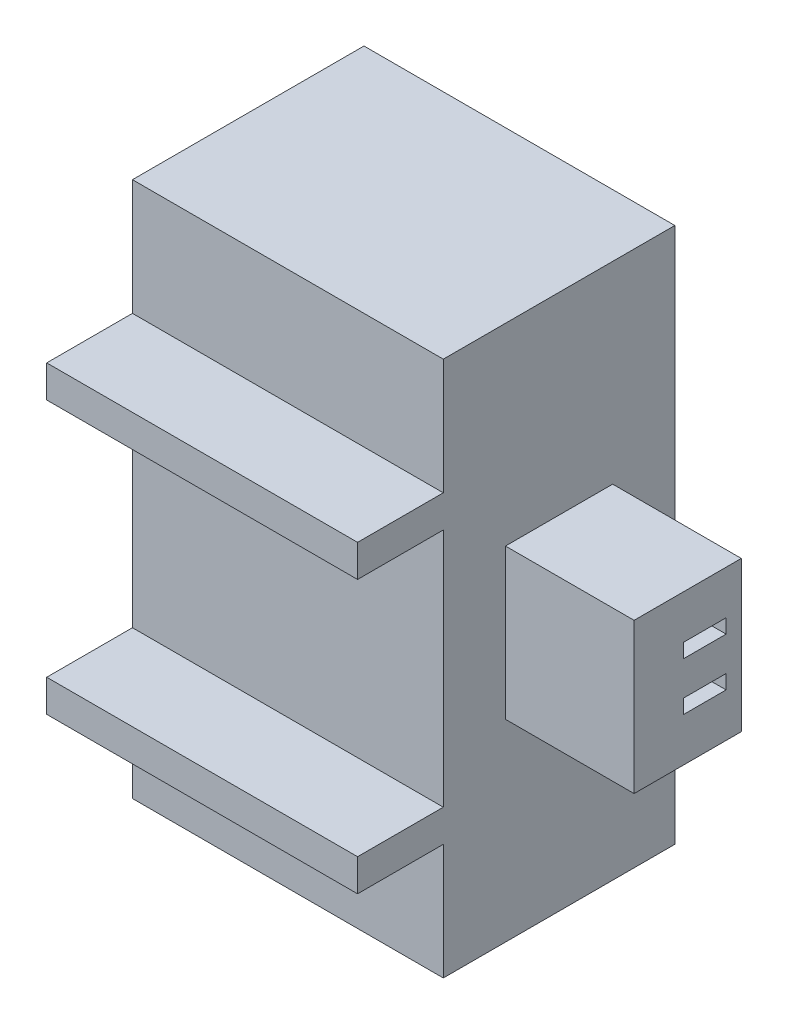
from build123d import *

# Parameters (mm, degrees)
SKETCH1_W           = 7.25
SKETCH1_H           = 12.5
BOSS_EXTRUDE1_DEPTH = 7.4
SKETCH2_W           = 2
SKETCH2_H           = 2.700167795
SKETCH2_H_2         = 5.59966441
CUT_EXTRUDE1_DEPTH  = 8.25
SKETCH3_W           = 2.5
SKETCH3_H           = 3.5
SKETCH3_W_2         = 1
SKETCH3_H_2         = 0.331350256
BOSS_EXTRUDE2_DEPTH = 3


with BuildPart() as part:
    # Sketch1 → Boss-Extrude1 (new body)
    with BuildSketch(Plane.XY):
        with Locations((3.625, 6.25)):
            Rectangle(SKETCH1_W, SKETCH1_H)
    extrude(amount=BOSS_EXTRUDE1_DEPTH)

    # Sketch2 → Cut-Extrude1 (cut, through all)
    with BuildSketch(Plane(origin=(7.25, 0, 0), x_dir=(0, 0, -1), z_dir=(1, 0, 0))):
        with Locations((-6.4, 11.149916103)):
            Rectangle(SKETCH2_W, SKETCH2_H)
        with Locations((-6.4, 1.350083898)):
            Rectangle(SKETCH2_W, SKETCH2_H)
        with Locations((-6.4, 6.25)):
            Rectangle(SKETCH2_W, SKETCH2_H_2)
    extrude(amount=-CUT_EXTRUDE1_DEPTH, mode=Mode.SUBTRACT)

    # Sketch3 → Boss-Extrude2 (add)
    with BuildSketch(Plane(origin=(7.25, 0, 0), x_dir=(0, 0, -1), z_dir=(1, 0, 0))):
        with Locations((-2.7, 6.25)):
            Rectangle(SKETCH3_W, SKETCH3_H)
        with Locations((-2.303664878, 5.686580017)):
            Rectangle(SKETCH3_W_2, SKETCH3_H_2, mode=Mode.SUBTRACT)
        with Locations((-2.303664878, 6.813419983)):
            Rectangle(SKETCH3_W_2, SKETCH3_H_2, mode=Mode.SUBTRACT)
    extrude(amount=BOSS_EXTRUDE2_DEPTH)


solid = part.part
